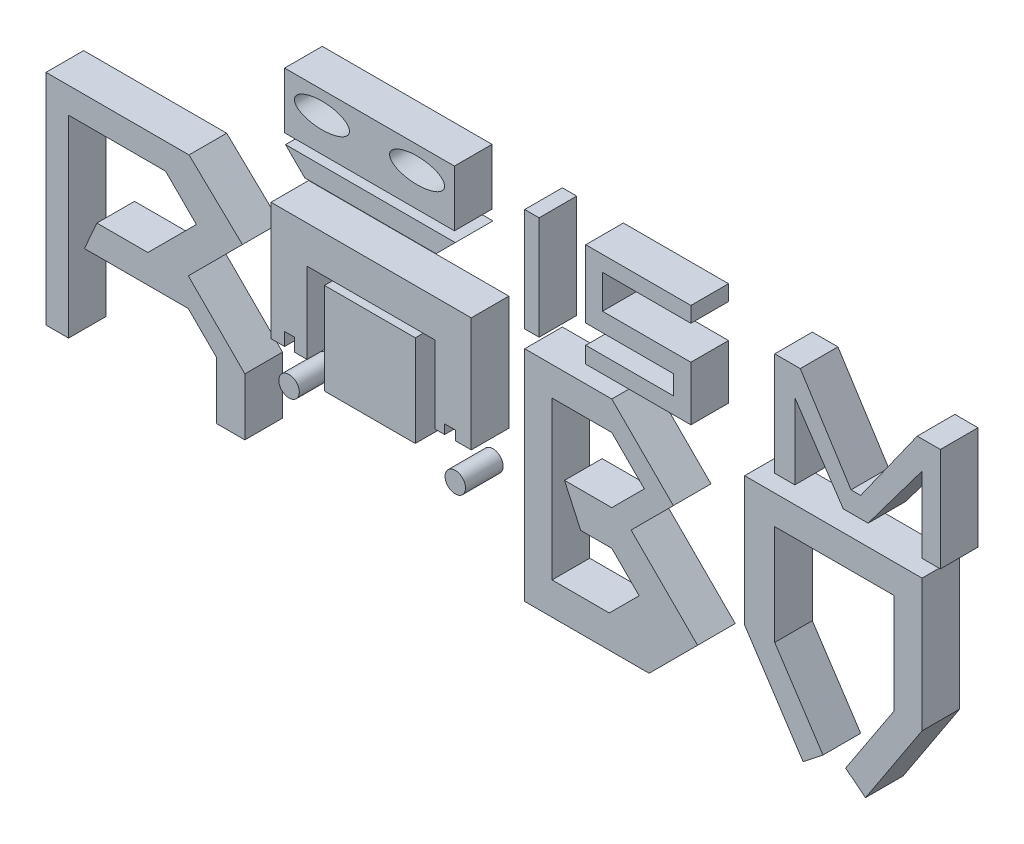
from build123d import *

# Parameters (mm, degrees)
BOSS_EXTRUDE3_DEPTH    = 5
BOSS_EXTRUDE3_2_DEPTH  = 5
SKETCH1_W              = 24.121739131
SKETCH1_H              = 24.317391305
BOSS_EXTRUDE3_3_DEPTH  = 5
BOSS_EXTRUDE3_4_DEPTH  = 5
BOSS_EXTRUDE3_5_DEPTH  = 5
BOSS_EXTRUDE3_6_DEPTH  = 5
BOSS_EXTRUDE3_7_DEPTH  = 5
SKETCH1_W_2            = 3.819491882
SKETCH1_H_2            = 27.485489058
BOSS_EXTRUDE3_8_DEPTH  = 5
SKETCH1_W_3            = 45.104347826
SKETCH1_H_3            = 14.908058774
SKETCH1_RX             = 7.313043478
SKETCH1_RY             = 3.304347826
BOSS_EXTRUDE3_9_DEPTH  = 5
SKETCH1_R              = 2.718976156
BOSS_EXTRUDE3_10_DEPTH = 5
BOSS_EXTRUDE3_11_DEPTH = 5
BOSS_EXTRUDE3_12_DEPTH = 5


with BuildPart() as part:
    # Sketch1 → Boss-Extrude3 (new body, symmetric)
    with BuildSketch(Plane.XY):
        Polygon((-120.27826087, 5.452173913), (-120.27826087, -9.747826087), (-127.795652174, -9.747826087), (-127.795652174, 5.452173913), (-135.313043478, 12.969565217), (-162.904347826, 12.969565217), (-159.6, 20.486956522), (-146.052173913, 20.486956522), (-133.165217391, 33.373913043), (-141.343478261, 41.552173913), (-167.117391304, 41.552173913), (-167.117391304, -9.747826087), (-173.117391304, -9.747826087), (-173.117391304, 48.408695652), (-135.117391304, 48.408695652), (-120.923913043, 34.876086957), (-135.313043478, 20.486956522), align=None)
    extrude(amount=BOSS_EXTRUDE3_DEPTH, both=True)


with BuildPart() as body_2:
    # Sketch1 → Boss-Extrude3 2 (new body, symmetric)
    with BuildSketch(Plane.XY):
        Polygon((-64.378336245, 20.486956522), (-64.378336245, 18.008695652), (-60.139130435, 18.008695652), (-60.139130435, 48.408695652), (-113.339130435, 48.408695652), (-113.339130435, 17.017391304), (-109.719350943, 17.017391304), (-109.719350943, 20.486956522), (-107.119350943, 20.486956522), (-107.119350943, 17.017391304), (-103.756521739, 17.017391304), (-103.756521739, 38.495652174), (-69.72173913, 38.495652174), (-69.72173913, 18.008695652), (-67.215003117, 18.008695652), (-67.215003117, 20.486956522), align=None)
    extrude(amount=BOSS_EXTRUDE3_2_DEPTH, both=True)


with BuildPart() as body_3:
    # Sketch1 → Boss-Extrude3 3 (new body, symmetric)
    with BuildSketch(Plane.XY):
        with Locations((-87.069565218, 24.219565218)):
            Rectangle(SKETCH1_W, SKETCH1_H)
    extrude(amount=BOSS_EXTRUDE3_3_DEPTH, both=True)


with BuildPart() as body_4:
    # Sketch1 → Boss-Extrude3 4 (new body, symmetric)
    with BuildSketch(Plane.XY):
        Polygon((-6.443478261, 32.052173913), (-22.8, 48.408695652), (-45.930434783, 48.408695652), (-45.930434783, -9.747826087), (-12.886956522, -9.747826087), (0, 3.139130435), (-17.67826087, 20.817391304), align=None)
        Polygon((-22.8, 40.695652174), (-38.660869565, 40.695652174), (-38.660869565, -1.156521739), (-23.460869565, -1.156521739), (-15.530434783, 6.773913043), (-22.8, 14.043478261), (-31.060869565, 14.043478261), (-35.356521739, 23.408695652), (-22.8, 23.408695652), (-14.156521739, 32.052173913), align=None, mode=Mode.SUBTRACT)
    extrude(amount=BOSS_EXTRUDE3_4_DEPTH, both=True)


with BuildPart() as body_5:
    # Sketch1 → Boss-Extrude3 5 (new body, symmetric)
    with BuildSketch(Plane.XY):
        Polygon((22.469565217, 48.408695652), (20.486956522, 48.408695652), (12.501449275, 48.408695652), (12.501449275, 14.043478261), (28.031884058, -9.622002049), (33.31884058, -5.453800649), (20.486956522, 14.043478261), (20.486956522, 40.695652174), (52.153623188, 40.695652174), (52.153623188, 14.043478261), (39.32173913, -5.453800649), (44.608695652, -9.622002049), (59.630424795, 13.268305931), (59.630424795, 48.408695652), align=None)
    extrude(amount=BOSS_EXTRUDE3_5_DEPTH, both=True)


with BuildPart() as body_6:
    # Sketch1 → Boss-Extrude3 6 (new body, symmetric)
    with BuildSketch(Plane.XY):
        Polygon((40.763008919, 59.289606781), (27.278060495, 80.44442172), (20.486956522, 80.44442172), (20.486956522, 52.958932662), (25.836790706, 52.958932662), (25.836790706, 73.025903847), (38.701020247, 53.882625327), (45.300153316, 53.882625327), (59.630424795, 73.025903847), (59.630424795, 52.958932662), (64.496708103, 52.958932662), (64.496708103, 80.44442172), (58.349410718, 80.44442172), (43.327681575, 59.289606781), align=None)
    extrude(amount=BOSS_EXTRUDE3_6_DEPTH, both=True)


with BuildPart() as body_7:
    # Sketch1 → Boss-Extrude3 7 (new body, symmetric)
    with BuildSketch(Plane.XY):
        Polygon((-6.443478261, 57.314414193), (-29.719943735, 57.314414193), (-29.719943735, 52.958932662), (-1.783872889, 52.958932662), (-1.783872889, 67.370018987), (-25.259184035, 67.370018987), (-25.259184035, 76.330251673), (-1.783872889, 76.330251673), (-1.783872889, 80.44442172), (-29.719943735, 80.44442172), (-29.719943735, 62.421150206), (-6.443478261, 62.421150206), align=None)
    extrude(amount=BOSS_EXTRUDE3_7_DEPTH, both=True)


with BuildPart() as body_8:
    # Sketch1 → Boss-Extrude3 8 (new body, symmetric)
    with BuildSketch(Plane.XY):
        with Locations((-44.020688842, 66.701677191)):
            Rectangle(SKETCH1_W_2, SKETCH1_H_2)
    extrude(amount=BOSS_EXTRUDE3_8_DEPTH, both=True)


with BuildPart() as body_9:
    # Sketch1 → Boss-Extrude3 9 (new body, symmetric)
    with BuildSketch(Plane.XY):
        with Locations((-87.16717703, 73.640714016)):
            Rectangle(SKETCH1_W_3, SKETCH1_H_3)
        with Locations((-99.806307464, 75.146917316)):
            Ellipse(SKETCH1_RX, SKETCH1_RY, mode=Mode.SUBTRACT)
        with Locations(Location((-74.528046595, 75.146917316), (0, 0, 180))):
            Ellipse(SKETCH1_RX, SKETCH1_RY, mode=Mode.SUBTRACT)
    extrude(amount=BOSS_EXTRUDE3_9_DEPTH, both=True)


with BuildPart() as body_10:
    # Sketch1 → Boss-Extrude3 10 (new body, symmetric)
    with BuildSketch(Plane.XY):
        with Locations((-108.537499539, 8.476225085)):
            Circle(SKETCH1_R)
    extrude(amount=BOSS_EXTRUDE3_10_DEPTH, both=True)


with BuildPart() as body_11:
    # Sketch1 → Boss-Extrude3 11 (new body, symmetric)
    with BuildSketch(Plane.XY):
        with Locations((-64.378336245, 8.476225085)):
            Circle(SKETCH1_R)
    extrude(amount=BOSS_EXTRUDE3_11_DEPTH, both=True)


with BuildPart() as body_12:
    # Sketch1 → Boss-Extrude3 12 (new body, symmetric)
    with BuildSketch(Plane.XY):
        Polygon((-109.482684071, 63.600618954), (-64.378336245, 63.600618954), (-69.485072259, 58.493882941), (-104.375948057, 58.493882941), align=None)
    extrude(amount=BOSS_EXTRUDE3_12_DEPTH, both=True)


solid = Compound([part.part, body_2.part, body_3.part, body_4.part, body_5.part, body_6.part, body_7.part, body_8.part, body_9.part, body_10.part, body_11.part, body_12.part])
